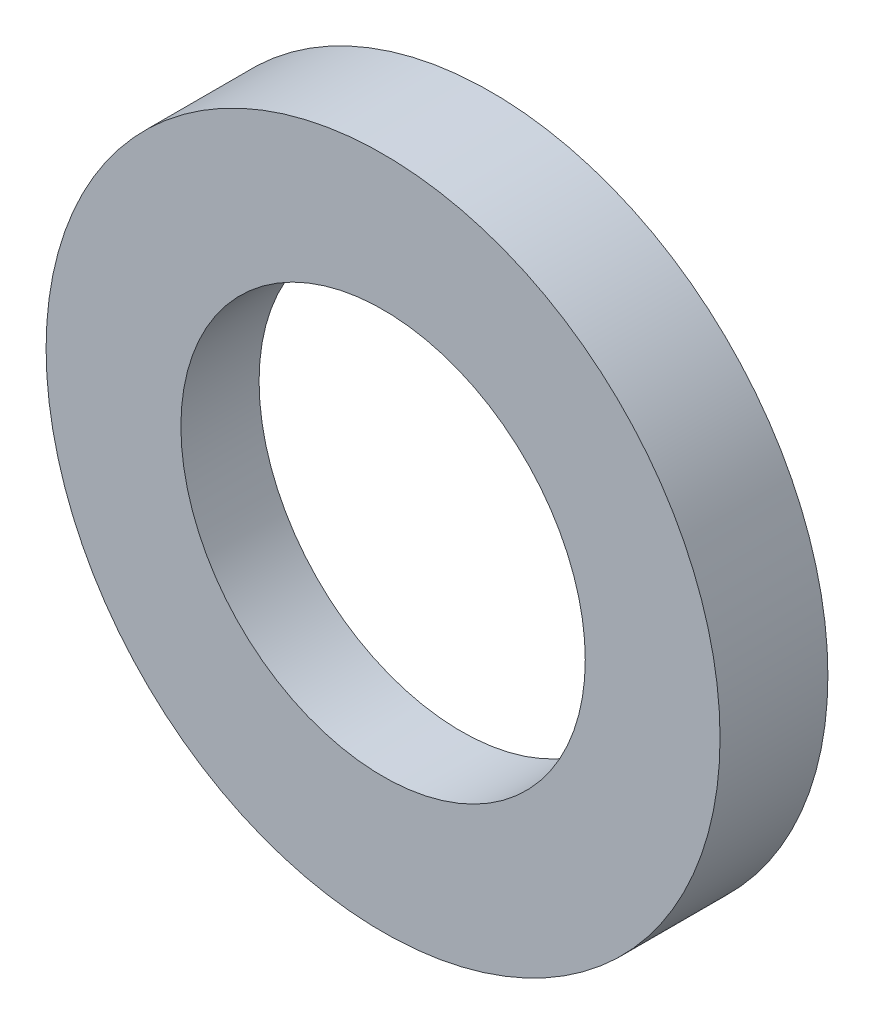
from build123d import *

# Parameters (mm, degrees)
SKETCH1_R           = 31.75
SKETCH1_R_2         = 19.05
BOSS_EXTRUDE1_DEPTH = 10.16
SKETCH2_R           = 25.4
SKETCH2_R_2         = 19.05
CUT_EXTRUDE1_DEPTH  = 2.794


with BuildPart() as part:
    # Sketch1 → Boss-Extrude1 (new body)
    with BuildSketch(Plane.XY):
        Circle(SKETCH1_R)
        Circle(SKETCH1_R_2, mode=Mode.SUBTRACT)
    extrude(amount=BOSS_EXTRUDE1_DEPTH)

    # Sketch2 → Cut-Extrude1 (cut)
    with BuildSketch(Plane(origin=(0, 0, 0), x_dir=(-1, 0, 0), z_dir=(0, 0, -1))):
        Circle(SKETCH2_R)
        Circle(SKETCH2_R_2, mode=Mode.SUBTRACT)
    extrude(amount=-CUT_EXTRUDE1_DEPTH, mode=Mode.SUBTRACT)


solid = part.part
